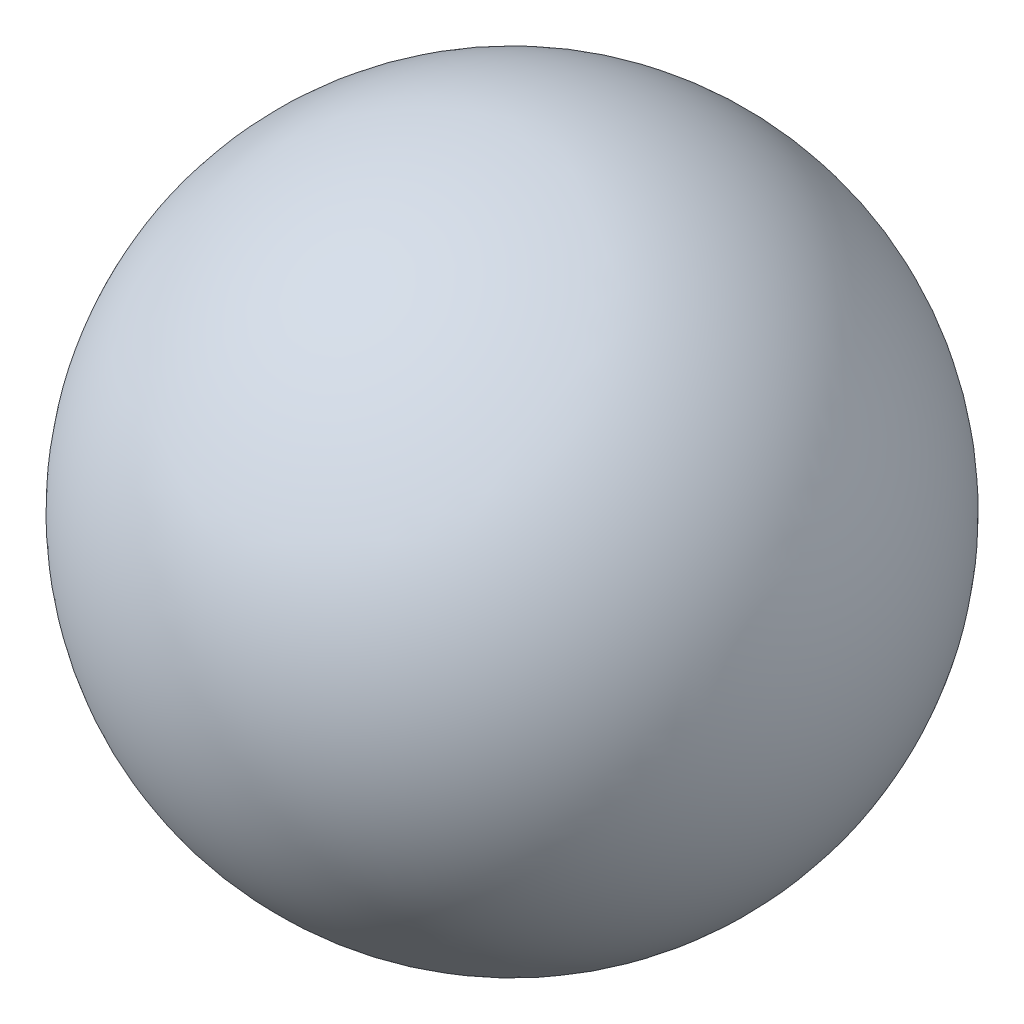
from build123d import *


with BuildPart() as part:
    # Esboço2 → Revolução1 (revolve)
    with BuildSketch(Plane.XY):
        with BuildLine():
            Line((25, 0), (-25, 0))
            ThreePointArc((-25, 0), (0, 25), (25, 0))
        make_face()
    revolve(axis=Axis((25, 0, 0), (-1, 0, 0)))


solid = part.part
